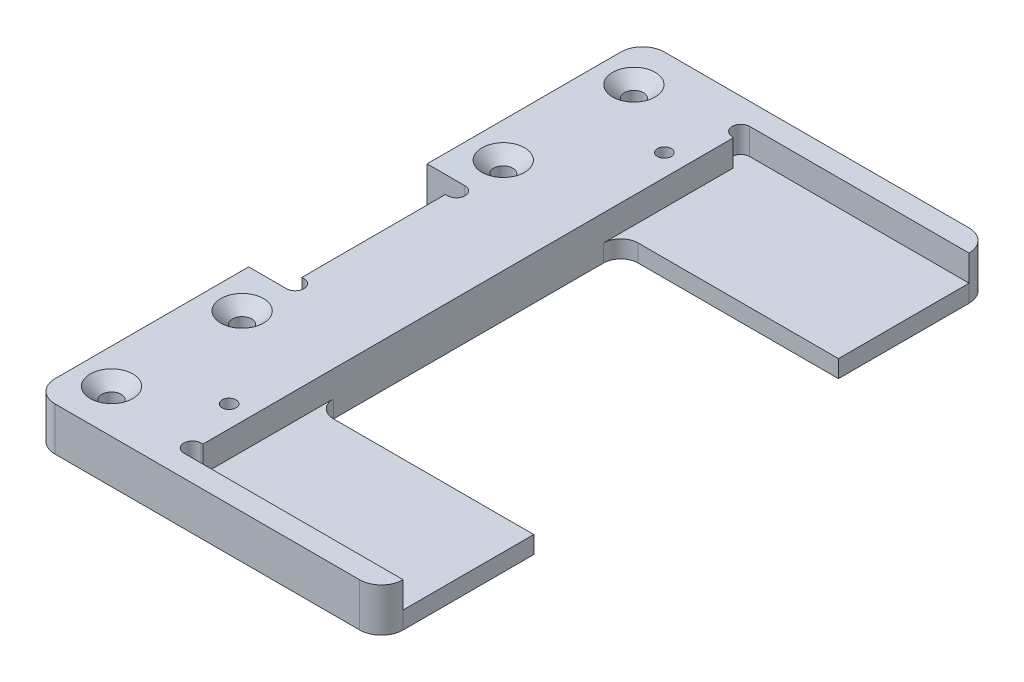
from build123d import *

# Parameters (mm, degrees)
BOSS_EXTRUDE1_DEPTH                                 = 5
FILLET1_R                                           = 2
FILLET2_R                                           = 2.5
CUT_EXTRUDE2_REACH                                  = 7
CSK_FOR_M2_COUNTERSUNK_FLAT_HEAD_SCREW1_D           = 2.2
CSK_FOR_M2_COUNTERSUNK_FLAT_HEAD_SCREW1_DEPTH       = 5
CSK_FOR_M2_COUNTERSUNK_FLAT_HEAD_SCREW1_CSINK_D     = 4.9
CSK_FOR_M2_COUNTERSUNK_FLAT_HEAD_SCREW1_CSINK_ANGLE = 90
M2_TAPPED_HOLE1_D                                   = 1.6
M2_TAPPED_HOLE1_DEPTH                               = 5
SKETCH9_W                                           = 25.2
SKETCH9_H                                           = 12.5
CUT_EXTRUDE3_DEPTH                                  = 1.25
CUT_EXTRUDE4_DEPTH                                  = 1.25
SKETCH11_W                                          = 25
SKETCH11_H                                          = 4.5
CUT_EXTRUDE5_DEPTH                                  = 1.25
BOSS_EXTRUDE2_DEPTH                                 = 1.25
CUT_EXTRUDE6_DEPTH                                  = 1.75


with BuildPart() as part:
    # Sketch1 → Boss-Extrude1 (new body)
    with BuildSketch(Plane(origin=(0, 0, 0), x_dir=(1, 0, 0), z_dir=(0, 1, 0))):
        Polygon((0, 35), (0, 10.25), (4.1, 10.25), (4.1, -10.25), (0, -10.25), (0, -35), (40, -35), (40, -17.5), (15, -17.5), (15, 17.5), (40, 17.5), (40, 35), align=None)
    extrude(amount=BOSS_EXTRUDE1_DEPTH)

    # Fillet1
    fillet1_edges = [part.edges().sort_by_distance(p)[0] for p in [
        (15, 2.5, -17.5),
        (15, 2.5, 17.5),
    ]]
    fillet(fillet1_edges, radius=FILLET1_R)

    # Fillet2
    fillet2_edges = [part.edges().sort_by_distance(p)[0] for p in [
        (0, 2.5, -35),
        (40, 2.5, -35),
        (40, 2.5, 35),
        (0, 2.5, 35),
    ]]
    fillet(fillet2_edges, radius=FILLET2_R)

    # Sketch3 → Cut-Extrude2 (cut, up to next)
    with BuildSketch(Plane(origin=(0, 5, 0), x_dir=(1, 0, 0), z_dir=(0, 1, 0)), mode=Mode.PRIVATE) as cut_extrude2_sk1:
        with BuildLine():
            Line((4.1, 10.25), (4.35, 10.25))
            ThreePointArc((4.35, 10.25), (5.35, 9.25), (4.35, 8.25))
            Line((4.35, 8.25), (4.1, 8.25))
            Line((4.1, 8.25), (4.1, 10.25))
        make_face()
    cut_extrude2_tool1 = extrude(cut_extrude2_sk1.sketch, amount=-CUT_EXTRUDE2_REACH, mode=Mode.PRIVATE) & part.part
    add(cut_extrude2_tool1.solids().sort_by_distance((4.641756, 5, -9.25))[0], mode=Mode.SUBTRACT)
    # Sketch3 → Cut-Extrude2 (cut, up to next)
    with BuildSketch(Plane(origin=(0, 5, 0), x_dir=(1, 0, 0), z_dir=(0, 1, 0)), mode=Mode.PRIVATE) as cut_extrude2_sk2:
        with BuildLine():
            Line((4.1, -10.25), (4.1, -8.25))
            Line((4.1, -8.25), (4.35, -8.25))
            ThreePointArc((4.35, -8.25), (5.35, -9.25), (4.35, -10.25))
            Line((4.35, -10.25), (4.1, -10.25))
        make_face()
    cut_extrude2_tool2 = extrude(cut_extrude2_sk2.sketch, amount=-CUT_EXTRUDE2_REACH, mode=Mode.PRIVATE) & part.part
    add(cut_extrude2_tool2.solids().sort_by_distance((4.641756, 5, 9.25))[0], mode=Mode.SUBTRACT)

    # CSK for M2 Countersunk Flat Head Screw1
    with Locations(Plane(origin=(0, 5, 0), x_dir=(1, 0, 0), z_dir=(0, 1, 0))):
        with Locations((4, 30), (4, 15), (4, -15), (4, -30)):
            csk_for_m2_countersunk_flat_head_screw1 = CounterSinkHole(CSK_FOR_M2_COUNTERSUNK_FLAT_HEAD_SCREW1_D / 2, CSK_FOR_M2_COUNTERSUNK_FLAT_HEAD_SCREW1_CSINK_D / 2, depth=CSK_FOR_M2_COUNTERSUNK_FLAT_HEAD_SCREW1_DEPTH, counter_sink_angle=CSK_FOR_M2_COUNTERSUNK_FLAT_HEAD_SCREW1_CSINK_ANGLE)

    # M2 Tapped Hole1
    with Locations(Plane(origin=(0, 5, 0), x_dir=(1, 0, 0), z_dir=(0, 1, 0))):
        with Locations((12.5, -25), (12.5, 25)):
            Hole(M2_TAPPED_HOLE1_D / 2, depth=M2_TAPPED_HOLE1_DEPTH)

    # Sketch9 → Cut-Extrude3 (cut)
    with BuildSketch(Plane(origin=(0, 5, 0), x_dir=(1, 0, 0), z_dir=(0, 1, 0))):
        with Locations((27.4, 26.25)):
            Rectangle(SKETCH9_W, SKETCH9_H)
        with Locations((27.4, -26.25)):
            Rectangle(SKETCH9_W, SKETCH9_H)
    extrude(amount=-CUT_EXTRUDE3_DEPTH, mode=Mode.SUBTRACT)

    # Sketch10 → Cut-Extrude4 (cut)
    with BuildSketch(Plane(origin=(0, 5, 0), x_dir=(1, 0, 0), z_dir=(0, 1, 0))):
        with BuildLine():
            Line((14.8, 22), (14.8, 20))
            ThreePointArc((14.8, 20), (13.8, 21), (14.8, 22))
        make_face()
        with BuildLine():
            Line((14.8, 30.5), (14.8, 32.5))
            ThreePointArc((14.8, 32.5), (13.8, 31.5), (14.8, 30.5))
        make_face()
    cut_extrude4 = extrude(amount=-CUT_EXTRUDE4_DEPTH, mode=Mode.SUBTRACT)

    # Mirror1: CSK for M2 Countersunk Flat Head Screw1 across plane
    add(csk_for_m2_countersunk_flat_head_screw1.mirror(Plane(origin=(0, 2.5, 0), x_dir=(0, 0, 1), z_dir=(0, -1, 0))), mode=Mode.SUBTRACT)

    # Mirror2: Cut-Extrude4 across plane
    add(cut_extrude4.mirror(Plane.XY), mode=Mode.SUBTRACT)

    # Sketch11 → Cut-Extrude5 (cut)
    with BuildSketch(Plane(origin=(0, 5, 0), x_dir=(1, 0, 0), z_dir=(0, 1, 0))):
        with Locations((27.5, 17.75)):
            Rectangle(SKETCH11_W, SKETCH11_H)
        with Locations((27.5, -17.75)):
            Rectangle(SKETCH11_W, SKETCH11_H)
    extrude(amount=-CUT_EXTRUDE5_DEPTH, mode=Mode.SUBTRACT)

    # Sketch12 → Boss-Extrude2 (add)
    with BuildSketch(Plane(origin=(0, 3.75, 0), x_dir=(1, 0, 0), z_dir=(0, 1, 0))):
        with BuildLine():
            Line((14.8, 20), (15, 20))
            Line((15, 20), (15, 30.37258082))
            Line((15, 30.37258082), (14.8, 30.5))
            Line((14.8, 30.5), (14.8, 22))
            ThreePointArc((14.8, 22), (13.8, 21), (14.8, 20))
        make_face()
        with BuildLine():
            Line((14.8, -20), (15, -20))
            Line((15, -20), (15, -30.5))
            Line((15, -30.5), (14.8, -30.5))
            Line((14.8, -30.5), (14.8, -22))
            ThreePointArc((14.8, -22), (13.8, -21), (14.8, -20))
        make_face()
    extrude(amount=BOSS_EXTRUDE2_DEPTH)

    # Sketch13 → Cut-Extrude6 (cut)
    with BuildSketch(Plane(origin=(0, 3.75, 0), x_dir=(1, 0, 0), z_dir=(0, 1, 0))):
        with BuildLine():
            Line((14.8, 30.5), (15, 30.37258082))
            Line((15, 30.37258082), (15, 15.5))
            ThreePointArc((15, 15.5), (15.585786438, 16.914213562), (17, 17.5))
            Line((17, 17.5), (40, 17.5))
            Line((40, 17.5), (40, 32.5))
            Line((40, 32.5), (14.8, 32.5))
            ThreePointArc((14.8, 32.5), (13.8, 31.5), (14.8, 30.5))
        make_face()
        with BuildLine():
            Line((15, -15.5), (15, -30.5))
            Line((15, -30.5), (14.8, -30.5))
            ThreePointArc((14.8, -30.5), (13.8, -31.5), (14.8, -32.5))
            Line((14.8, -32.5), (40, -32.5))
            Line((40, -32.5), (40, -17.5))
            Line((40, -17.5), (17, -17.5))
            ThreePointArc((17, -17.5), (15.585786438, -16.914213562), (15, -15.5))
        make_face()
    extrude(amount=-CUT_EXTRUDE6_DEPTH, mode=Mode.SUBTRACT)


solid = part.part
